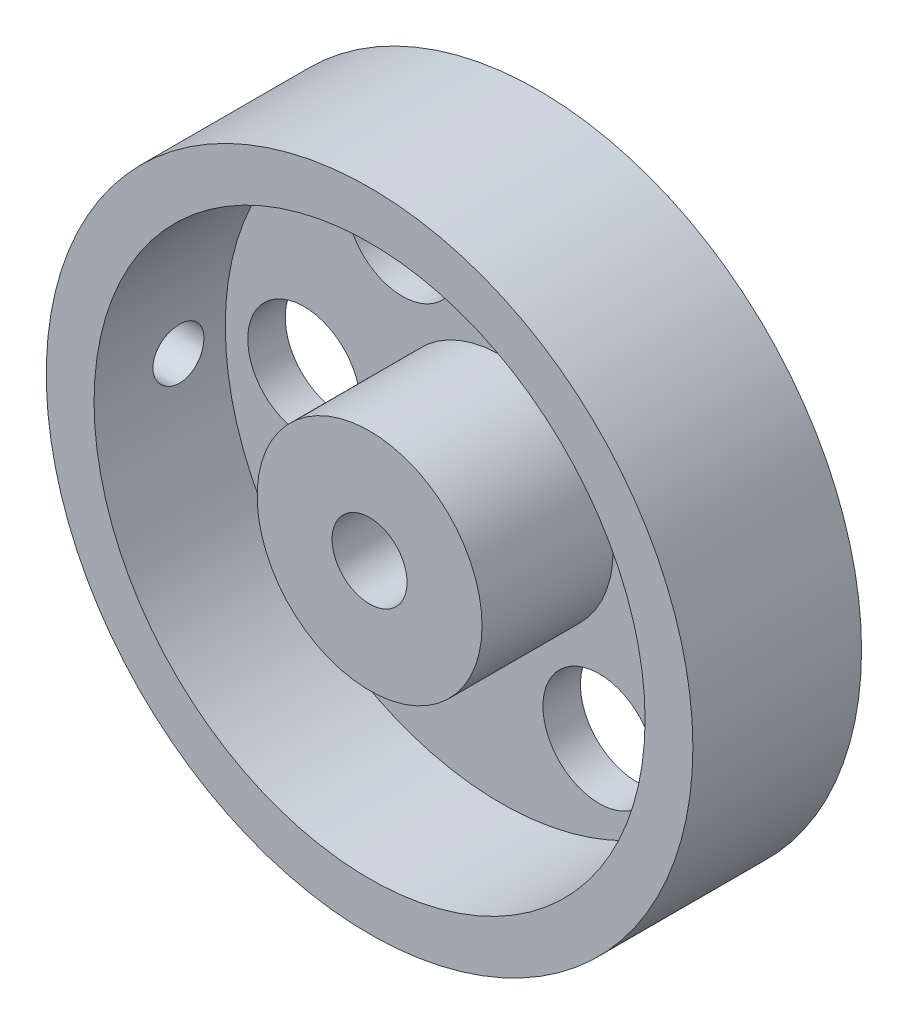
from build123d import *

# Parameters (mm, degrees)
SKETCH1_R           = 17.25
BOSS_EXTRUDE1_DEPTH = 4.5
SKETCH2_R           = 2
CUT_EXTRUDE1_DEPTH  = 9
SKETCH3_R           = 14.7
SKETCH3_R_2         = 6
CUT_EXTRUDE2_DEPTH  = 7
CUT_EXTRUDE3_REACH  = 4
SKETCH4_R           = 3
SKETCH5_R           = 1.35933313
CUT_EXTRUDE4_DEPTH  = 18


with BuildPart() as part:
    # Sketch1 → Boss-Extrude1 (new body, symmetric)
    with BuildSketch(Plane.XY):
        Circle(SKETCH1_R)
    extrude(amount=BOSS_EXTRUDE1_DEPTH, both=True)

    # Sketch2 → Cut-Extrude1 (cut)
    with BuildSketch(Plane.XY.offset(4.5)):
        Circle(SKETCH2_R)
    extrude(amount=-CUT_EXTRUDE1_DEPTH, mode=Mode.SUBTRACT)

    # Sketch3 → Cut-Extrude2 (cut)
    with BuildSketch(Plane.XY.offset(4.5)):
        Circle(SKETCH3_R)
        Circle(SKETCH3_R_2, mode=Mode.SUBTRACT)
    extrude(amount=-CUT_EXTRUDE2_DEPTH, mode=Mode.SUBTRACT)

    # Sketch4 → Cut-Extrude3 (cut, up to next)
    with BuildSketch(Plane.XY.offset(-2.5), mode=Mode.PRIVATE) as cut_extrude3_sk1:
        with Locations((10.5, 0)):
            Circle(SKETCH4_R)
    cut_extrude3_tool1 = extrude(cut_extrude3_sk1.sketch, amount=-CUT_EXTRUDE3_REACH, mode=Mode.PRIVATE) & part.part
    add(cut_extrude3_tool1.solids().sort_by_distance((10.5, 0, -2.5))[0], mode=Mode.SUBTRACT)
    # Sketch4 → Cut-Extrude3 (cut, up to next)
    with BuildSketch(Plane.XY.offset(-2.5), mode=Mode.PRIVATE) as cut_extrude3_sk2:
        with Locations((5.25, -9.09326674)):
            Circle(SKETCH4_R)
    cut_extrude3_tool2 = extrude(cut_extrude3_sk2.sketch, amount=-CUT_EXTRUDE3_REACH, mode=Mode.PRIVATE) & part.part
    add(cut_extrude3_tool2.solids().sort_by_distance((5.25, -9.093267, -2.5))[0], mode=Mode.SUBTRACT)
    # Sketch4 → Cut-Extrude3 (cut, up to next)
    with BuildSketch(Plane.XY.offset(-2.5), mode=Mode.PRIVATE) as cut_extrude3_sk3:
        with Locations((-5.25, -9.09326674)):
            Circle(SKETCH4_R)
    cut_extrude3_tool3 = extrude(cut_extrude3_sk3.sketch, amount=-CUT_EXTRUDE3_REACH, mode=Mode.PRIVATE) & part.part
    add(cut_extrude3_tool3.solids().sort_by_distance((-5.25, -9.093267, -2.5))[0], mode=Mode.SUBTRACT)
    # Sketch4 → Cut-Extrude3 (cut, up to next)
    with BuildSketch(Plane.XY.offset(-2.5), mode=Mode.PRIVATE) as cut_extrude3_sk4:
        with Locations((-10.5, 0)):
            Circle(SKETCH4_R)
    cut_extrude3_tool4 = extrude(cut_extrude3_sk4.sketch, amount=-CUT_EXTRUDE3_REACH, mode=Mode.PRIVATE) & part.part
    add(cut_extrude3_tool4.solids().sort_by_distance((-10.5, 0, -2.5))[0], mode=Mode.SUBTRACT)
    # Sketch4 → Cut-Extrude3 (cut, up to next)
    with BuildSketch(Plane.XY.offset(-2.5), mode=Mode.PRIVATE) as cut_extrude3_sk5:
        with Locations((-5.25, 9.09326674)):
            Circle(SKETCH4_R)
    cut_extrude3_tool5 = extrude(cut_extrude3_sk5.sketch, amount=-CUT_EXTRUDE3_REACH, mode=Mode.PRIVATE) & part.part
    add(cut_extrude3_tool5.solids().sort_by_distance((-5.25, 9.093267, -2.5))[0], mode=Mode.SUBTRACT)
    # Sketch4 → Cut-Extrude3 (cut, up to next)
    with BuildSketch(Plane.XY.offset(-2.5), mode=Mode.PRIVATE) as cut_extrude3_sk6:
        with Locations((5.25, 9.09326674)):
            Circle(SKETCH4_R)
    cut_extrude3_tool6 = extrude(cut_extrude3_sk6.sketch, amount=-CUT_EXTRUDE3_REACH, mode=Mode.PRIVATE) & part.part
    add(cut_extrude3_tool6.solids().sort_by_distance((5.25, 9.093267, -2.5))[0], mode=Mode.SUBTRACT)

    # Sketch5 → Cut-Extrude4 (cut)
    with BuildSketch(Plane(origin=(0, 0, 0), x_dir=(0, 0, -1), z_dir=(1, 0, 0))):
        Circle(SKETCH5_R)
    extrude(amount=-CUT_EXTRUDE4_DEPTH, mode=Mode.SUBTRACT)


solid = part.part
